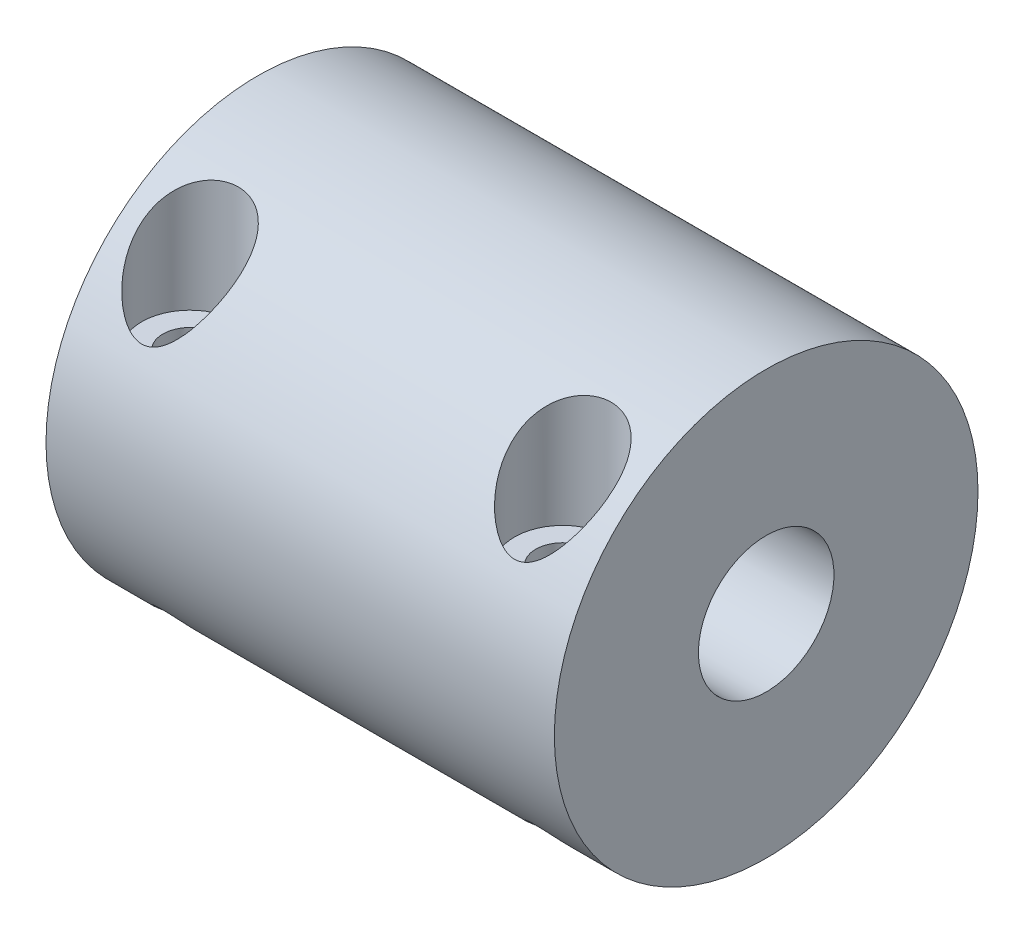
from build123d import *

# Parameters (mm, degrees)
SKETCH_2_R                = 1.6
CUT_EXTRUDE_M3_DEPTH      = 13.5
CUT_EXTRUDE_M3_DEPTH_BACK = 13.5
SKETCH_3_R                = 2.85
CUT_EXTRUDE_993_DEPTH     = 8


with BuildPart() as part:
    # 草图1 → Revolve 643 (revolve)
    with BuildSketch(Plane(origin=(0, 0, 0), x_dir=(1, 0, 0), z_dir=(0, 1, 0))):
        Polygon((0, 12.5), (0, 3), (15, 3), (15, 4), (30, 4), (30, 12.5), align=None)
    revolve(axis=Axis((-118.9426696, 0, 0), (1, 0, 0)))

    # 草图2 → M3孔 (cut, two sides)
    with BuildSketch(Plane(origin=(0, 0, 0), x_dir=(1, 0, 0), z_dir=(0, 1, 0))) as cut_extrude_m3_sk:
        with Locations((4, -8)):
            Circle(SKETCH_2_R)
        with Locations((26, -8)):
            Circle(SKETCH_2_R)
    extrude(amount=CUT_EXTRUDE_M3_DEPTH, mode=Mode.SUBTRACT)
    extrude(cut_extrude_m3_sk.sketch, amount=-CUT_EXTRUDE_M3_DEPTH_BACK, mode=Mode.SUBTRACT)

    # 草图3 → Cut-Extrude 993 (cut)
    with BuildSketch(Plane(origin=(0, 12.499395806, 0), x_dir=(1, 0, 0), z_dir=(0, 1, 0))):
        with Locations((4, -8)):
            Circle(SKETCH_3_R)
        with Locations((26, -8)):
            Circle(SKETCH_3_R)
    extrude(amount=-CUT_EXTRUDE_993_DEPTH, mode=Mode.SUBTRACT)


solid = part.part
